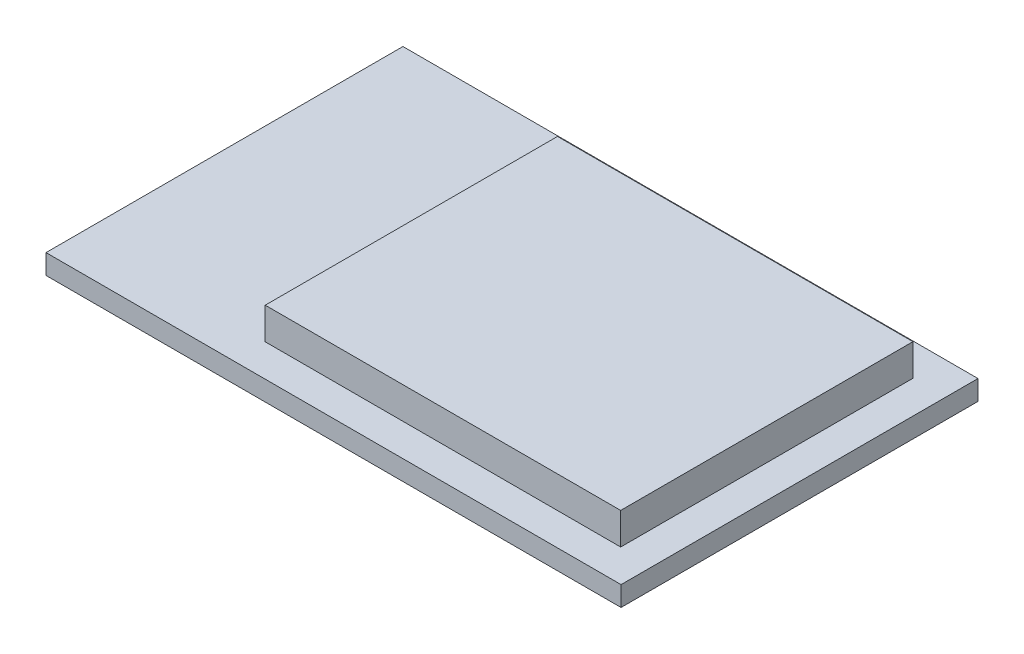
from build123d import *

# Parameters (mm, degrees)
SKETCH_1_W      = 29
SKETCH_1_H      = 18
EXTRUDE_1_DEPTH = 1
SKETCH_2_W      = 17.925
SKETCH_2_H      = 14.738319606
EXTRUDE_2_DEPTH = 1.6


with BuildPart() as part:
    # Эскиз1 → Бобышка-Вытянуть1 (new body)
    with BuildSketch(Plane(origin=(0, 0, 0), x_dir=(1, 0, 0), z_dir=(0, 1, 0))):
        Rectangle(SKETCH_1_W, SKETCH_1_H)
    extrude(amount=EXTRUDE_1_DEPTH)

    # Эскиз2 → Бобышка-Вытянуть2 (add)
    with BuildSketch(Plane(origin=(0, 1, 0), x_dir=(1, 0, 0), z_dir=(0, 1, 0))):
        with Locations((3.8875, 0)):
            Rectangle(SKETCH_2_W, SKETCH_2_H)
    extrude(amount=EXTRUDE_2_DEPTH)


solid = part.part
